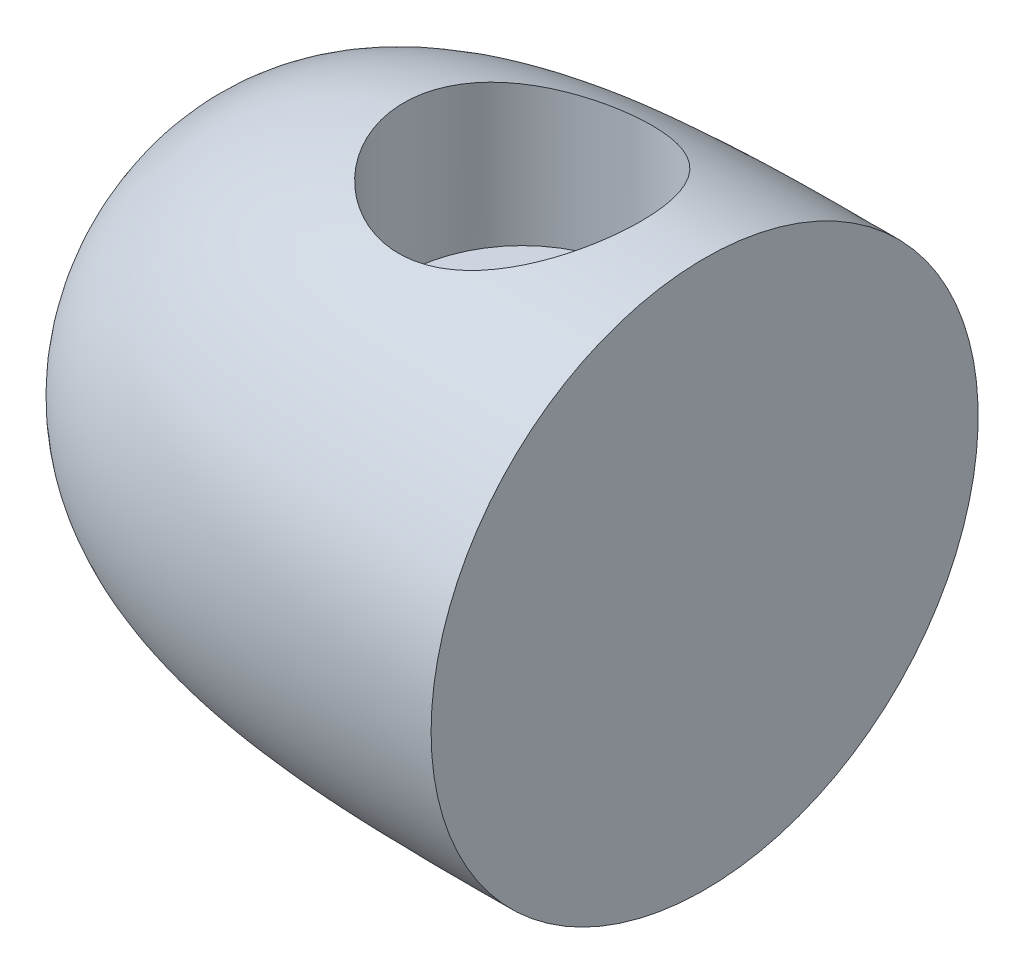
from build123d import *

# Parameters (mm, degrees)
SKETCH3_R          = 8.255
CUT_EXTRUDE2_DEPTH = 12.430942443
SKETCH4_R          = 12.397062146
CUT_EXTRUDE3_DEPTH = 10


with BuildPart() as part:
    # Sketch1 → Revolve1 (revolve)
    with BuildSketch(Plane.XY):
        with BuildLine():
            Line((-38.1, 0), (0, 0))
            Line((0, 0), (0, 19.05))
            add(Edge.make_bspline(
                [(-38.1, 0), (-38.1, 19.511634231), (-17.237160038, 19.05), (0, 19.05)],
                knots=[0, 0, 0, 0, 1, 1, 1, 1], degree=3))
        make_face()
    revolve(axis=Axis((-71.948497854, 0, 0), (1, 0, 0)))

    # Sketch3 → Cut-Extrude2 (cut, through all)
    with BuildSketch(Plane(origin=(0, 7.62, 0), x_dir=(1, 0, 0), z_dir=(0, 1, 0))):
        with Locations((-12.7, 0)):
            Circle(SKETCH3_R)
    extrude(amount=CUT_EXTRUDE2_DEPTH, mode=Mode.SUBTRACT)

    # Sketch4 → Cut-Extrude3 (cut)
    with BuildSketch(Plane(origin=(-37, 0, 0), x_dir=(0, 0, -1), z_dir=(1, 0, 0))):
        Circle(SKETCH4_R)
    extrude(amount=-CUT_EXTRUDE3_DEPTH, mode=Mode.SUBTRACT)


solid = part.part
